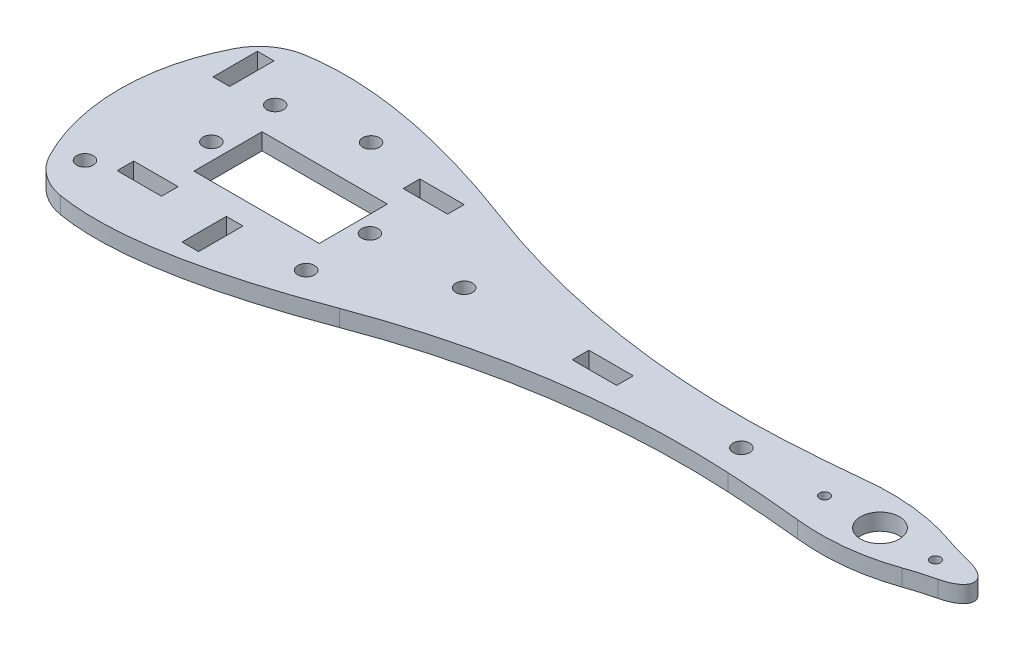
from build123d import *

# Parameters (mm, degrees)
ESBO_O1_R                = 1.5
ESBO_O1_R_2              = 3.5
ESBO_O1_R_3              = 0.9
ESBO_O1_W                = 22.6
ESBO_O1_H                = 12.3
ESBO_O1_W_2              = 3
ESBO_O1_H_2              = 8
ESBO_O1_W_3              = 8
ESBO_O1_H_3              = 3
RESSALTO_EXTRUS_O1_DEPTH = 3


with BuildPart() as part:
    # Esboço1 → Ressalto-extrusão1 (new body)
    with BuildSketch(Plane(origin=(0, 0, 0), x_dir=(1, 0, 0), z_dir=(0, 1, 0))):
        with BuildLine():
            ThreePointArc((-26.75078073, 16.719697214), (-30.815641586, -2.3e-07), (-26.750780519, -16.719697622))
            ThreePointArc((-26.750780519, -16.719697622), (-23.767751269, -20.202130616), (-19.544028371, -21.987058612))
            add(Edge.make_bspline(
                [(23.247280819, -14.466941833), (22.21541658, -14.85491506), (7.843575487, -20.128766531), (-8.032505645, -23.945383183), (-19.544028371, -21.987058612)],
                knots=[0.1894974, 0.1894974, 0.1894974, 0.1894974, 0.216439611, 0.561126756, 0.561126756, 0.561126756, 0.561126756], degree=3))
            ThreePointArc((23.247280819, -14.466941833), (53.114593998, -6.632399806), (83.953283265, -5.079438247))
            add(Edge.make_bspline(
                [(97.598521861, -6.15), (93.039003458, -5.676054912), (88.490590593, -5.319200994), (83.953283265, -5.079438247)],
                knots=[0, 0, 0, 0, 0.137959586, 0.137959586, 0.137959586, 0.137959586], degree=3))
            add(Edge.make_bspline(
                [(114.569723425, -4.259468977), (109.134912936, -6.157348784), (103.477845748, -6.787525792), (97.598521861, -6.15)],
                knots=[0.35388944, 0.35388944, 0.35388944, 0.35388944, 1, 1, 1, 1], degree=3))
            ThreePointArc((114.569723425, -4.259468977), (117.037611185, -3.468795912), (119.543150354, -2.807050219))
            add(Edge.make_bspline(
                [(119.543150354, -2.807050219), (131.408766059, 0), (119.543150354, 2.807050219)],
                knots=[5.194112445, 5.194112445, 5.194112445, 7.372258169, 7.372258169, 7.372258169], degree=2, weights=[1, 0.463307193, 1]))
            ThreePointArc((119.543150354, 2.807050219), (117.037611185, 3.468795912), (114.569723425, 4.259468977))
            add(Edge.make_bspline(
                [(114.569723425, 4.259468977), (109.134912936, 6.157348784), (103.477845748, 6.787525792), (97.598521861, 6.15)],
                knots=[0.35388944, 0.35388944, 0.35388944, 0.35388944, 1, 1, 1, 1], degree=3))
            add(Edge.make_bspline(
                [(97.598521861, 6.15), (93.039003574, 5.676054924), (88.490590825, 5.319201013), (83.953283612, 5.079438265)],
                knots=[0, 0, 0, 0, 0.137959582, 0.137959582, 0.137959582, 0.137959582], degree=3))
            ThreePointArc((83.953283612, 5.079438265), (53.114594943, 6.632399691), (23.24728229, 14.466941345))
            add(Edge.make_bspline(
                [(23.24728229, 14.466941345), (22.21541757, 14.854914742), (7.843576153, 20.128766099), (-8.032505406, 23.945382333), (-19.544028008, 21.987058404)],
                knots=[0.189497388, 0.189497388, 0.189497388, 0.189497388, 0.216439611, 0.561126752, 0.561126752, 0.561126752, 0.561126752], degree=3))
            ThreePointArc((-19.544028008, 21.987058404), (-23.767751262, 20.202130438), (-26.75078073, 16.719697214))
        make_face()
        with Locations((-14.3, 0)):
            Circle(ESBO_O1_R, mode=Mode.SUBTRACT)
        with Locations((14.3, 0)):
            Circle(ESBO_O1_R, mode=Mode.SUBTRACT)
        with Locations((0.2, 14.3)):
            Circle(ESBO_O1_R, mode=Mode.SUBTRACT)
        with Locations((-22.8, -14.3)):
            Circle(ESBO_O1_R, mode=Mode.SUBTRACT)
        with Locations((-14.3, 11.5)):
            Circle(ESBO_O1_R, mode=Mode.SUBTRACT)
        with Locations((14.3, -11.5)):
            Circle(ESBO_O1_R, mode=Mode.SUBTRACT)
        with Locations((106.3, 0)):
            Circle(ESBO_O1_R_2, mode=Mode.SUBTRACT)
        with Locations((96.3, 0)):
            Circle(ESBO_O1_R_3, mode=Mode.SUBTRACT)
        with Locations((116.3, 0)):
            Circle(ESBO_O1_R_3, mode=Mode.SUBTRACT)
        with Locations((31.3, 0)):
            Circle(ESBO_O1_R, mode=Mode.SUBTRACT)
        with Locations((81.3, 0)):
            Circle(ESBO_O1_R, mode=Mode.SUBTRACT)
        Rectangle(ESBO_O1_W, ESBO_O1_H, mode=Mode.SUBTRACT)
        with Locations((0.2, -14.3)):
            Rectangle(ESBO_O1_W_2, ESBO_O1_H_2, mode=Mode.SUBTRACT)
        with Locations((-22.8, 14.3)):
            Rectangle(ESBO_O1_W_2, ESBO_O1_H_2, mode=Mode.SUBTRACT)
        with Locations((14.3, 11.500000009)):
            Rectangle(ESBO_O1_W_3, ESBO_O1_H_3, mode=Mode.SUBTRACT)
        with Locations((-14.3, -11.5)):
            Rectangle(ESBO_O1_W_3, ESBO_O1_H_3, mode=Mode.SUBTRACT)
        Polygon((56.3, -1.5), (60.3, -1.5), (60.3, 1.5), (52.3, 1.5), (52.3, -1.5), align=None, mode=Mode.SUBTRACT)
    extrude(amount=RESSALTO_EXTRUS_O1_DEPTH)


solid = part.part
